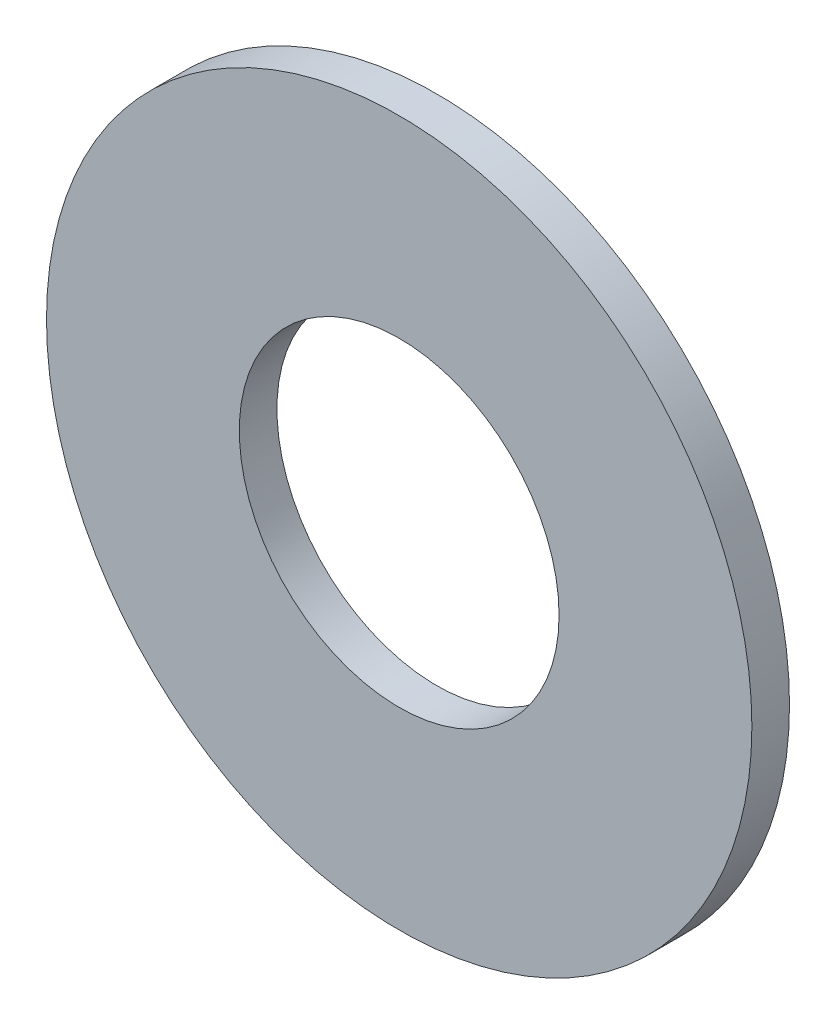
from build123d import *

# Parameters (mm, degrees)
SKETCH1_R      = 4.7625
SKETCH1_R_2    = 2.159
EXTRUDE1_DEPTH = 0.508


with BuildPart() as part:
    # Sketch1 → Extrude1 (new body)
    with BuildSketch(Plane.XY):
        Circle(SKETCH1_R)
        Circle(SKETCH1_R_2, mode=Mode.SUBTRACT)
    extrude(amount=-EXTRUDE1_DEPTH)


solid = part.part
